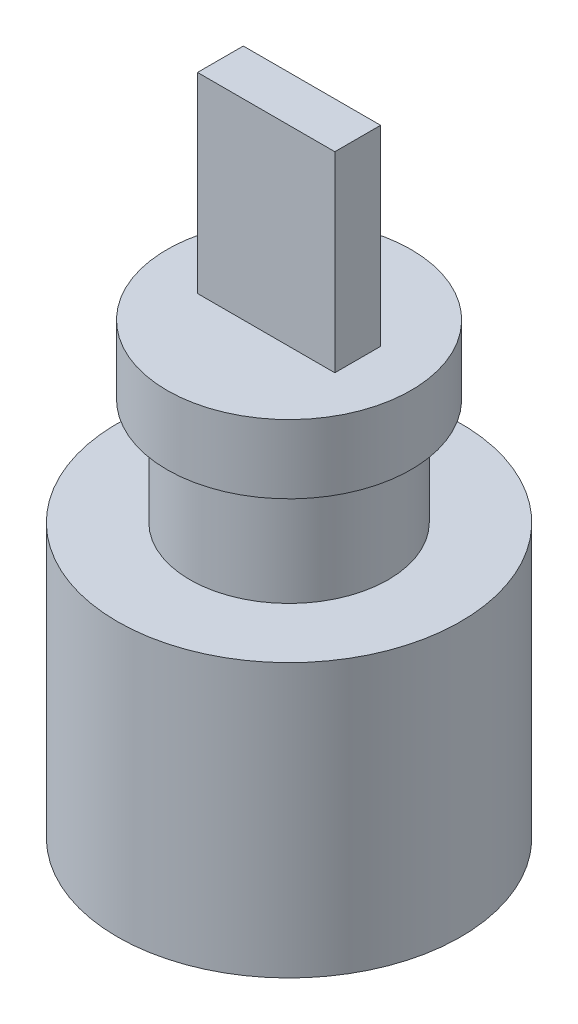
from build123d import *

# Parameters (mm, degrees)
SCHIZZO1_R                   = 22.5
ESTRUSIONE_ESTRUSIONE1_DEPTH = 35.8
SCHIZZO2_R                   = 13
ESTRUSIONE_ESTRUSIONE3_DEPTH = 14
SCHIZZO3_R                   = 16
ESTRUSIONE_ESTRUSIONE4_DEPTH = 9
SCHIZZO4_W                   = 18
SCHIZZO4_H                   = 6
ESTRUSIONE_ESTRUSIONE5_DEPTH = 25.1


with BuildPart() as part:
    # Schizzo1 → Estrusione-Estrusione1 (new body)
    with BuildSketch(Plane(origin=(0, 0, 0), x_dir=(1, 0, 0), z_dir=(0, 1, 0))):
        Circle(SCHIZZO1_R)
    extrude(amount=ESTRUSIONE_ESTRUSIONE1_DEPTH)

    # Schizzo2 → Estrusione-Estrusione3 (add)
    with BuildSketch(Plane(origin=(0, 35.8, 0), x_dir=(1, 0, 0), z_dir=(0, 1, 0))):
        Circle(SCHIZZO2_R)
    extrude(amount=ESTRUSIONE_ESTRUSIONE3_DEPTH)

    # Schizzo3 → Estrusione-Estrusione4 (add)
    with BuildSketch(Plane(origin=(0, 49.8, 0), x_dir=(1, 0, 0), z_dir=(0, 1, 0))):
        Circle(SCHIZZO3_R)
    extrude(amount=ESTRUSIONE_ESTRUSIONE4_DEPTH)

    # Schizzo4 → Estrusione-Estrusione5 (add)
    with BuildSketch(Plane(origin=(0, 58.8, 0), x_dir=(1, 0, 0), z_dir=(0, 1, 0))):
        Rectangle(SCHIZZO4_W, SCHIZZO4_H)
    extrude(amount=ESTRUSIONE_ESTRUSIONE5_DEPTH)


solid = part.part
